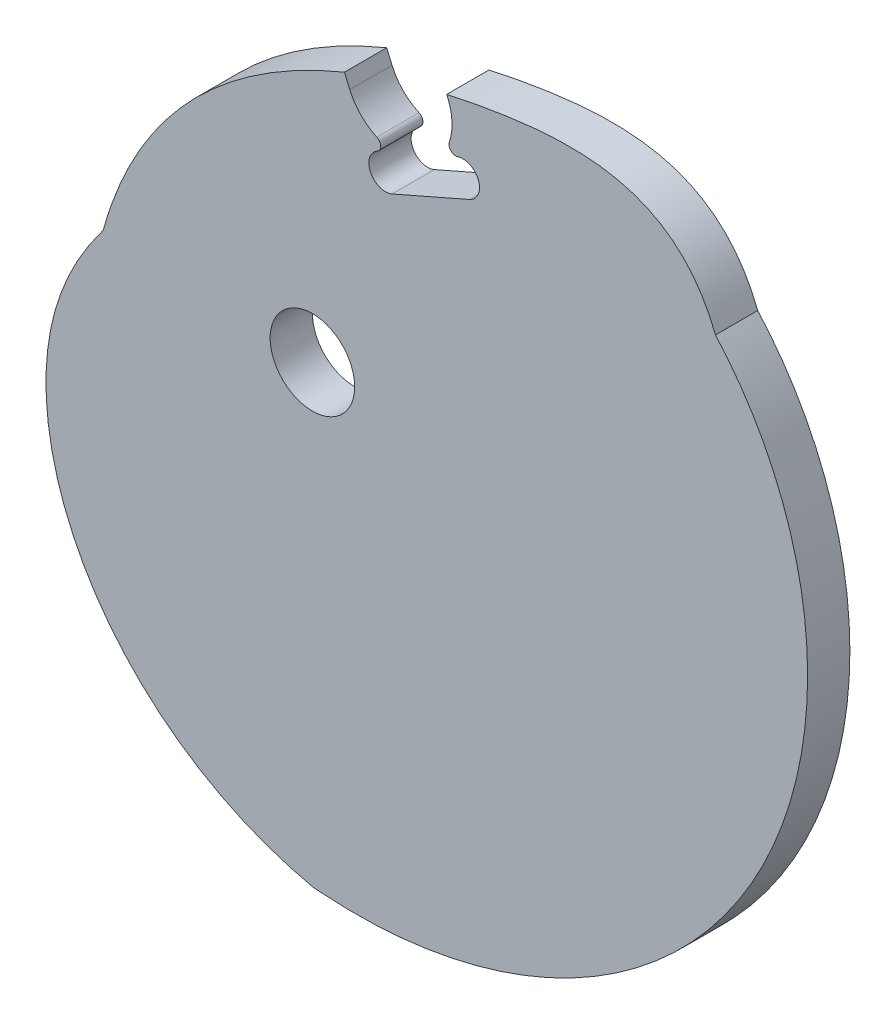
from build123d import *

# Parameters (mm, degrees)
SKETCH1_R           = 6.35
BOSS_EXTRUDE1_DEPTH = 3.175
FILLET3_R           = 1


with BuildPart() as part:
    # Sketch1 → Boss-Extrude1 (new body, symmetric)
    with BuildSketch(Plane.XY):
        with BuildLine():
            ThreePointArc((11.984914181, 27.895733584), (8.691133377, 29.180649151), (9.976048944, 32.474429955))
            Line((9.976048944, 32.474429955), (12.234616787, 33.465357952))
            ThreePointArc((12.234616787, 33.465357952), (8.260068693, 34.969173795), (5.615202157, 38.295309036))
            Line((5.615202157, 38.295309036), (4.817017743, 40.166741189))
            add(Edge.make_bspline(
                [(4.817017743, 40.166741189), (-12.318313017, 33.133186073), (-26.082330189, 20.886296157), (-31.434854064, 1.476615471)],
                knots=[0.525970045, 0.525970045, 0.525970045, 0.525970045, 1, 1, 1, 1], degree=3))
            add(Edge.make_bspline(
                [(-31.434854064, 1.476615471), (-31.527195505, 1.353858054), (-31.754298965, 1.049739376), (-32.114304, 0.558316675), (-32.5147745, -0.002107391), (-32.914270808, -0.576495389), (-33.311891924, -1.165119679), (-33.706725269, -1.768206694), (-34.097848502, -2.385936616), (-34.484331346, -3.018443117), (-34.865237427, -3.665813149), (-35.239626109, -4.328086807), (-35.606554333, -5.005257241), (-35.965078463, -5.697270632), (-36.433186951, -6.644749058), (-36.877778588, -7.616227649), (-37.403538549, -8.865808487), (-37.89844649, -10.15596349), (-38.339644059, -11.47844157), (-38.659981536, -12.561345718), (-38.883742195, -13.388599922), (-39.089211509, -14.227060001), (-39.27554788, -15.076191498), (-39.498552768, -16.225715183), (-39.726946666, -17.686700696), (-39.917996988, -19.468580741), (-40.024782444, -21.280969713), (-40.045341441, -23.119742437), (-39.9779185, -24.980664299), (-39.820968297, -26.859401742), (-39.573161339, -28.751532609), (-39.233388685, -30.652556865), (-38.800766241, -32.557907545), (-38.274638487, -34.462961931), (-37.654581673, -36.363052938), (-36.940406441, -38.253480666), (-36.132159895, -40.129524105), (-35.230127076, -41.986452952), (-34.234831872, -43.819539532), (-33.147037329, -45.624070773), (-31.967745371, -47.395360218), (-30.69819593, -49.128760047), (-29.339865478, -50.819673076), (-27.894464961, -52.463564698), (-26.363937143, -54.055974755), (-24.750453354, -55.592529291), (-23.05640966, -57.068952172), (-21.284422438, -58.481076539), (-19.437323392, -59.824856061), (-17.518153991, -61.09637597), (-15.53015936, -62.291863846), (-13.476781624, -63.407700126), (-11.361652741, -64.440428475), (-9.553831313, -65.227709289), (-8.080597677, -65.813060218), (-6.960835983, -66.230097397), (-5.828609099, -66.623940834), (-4.684517393, -66.994692102), (-3.528855098, -67.340343758), (-2.363108933, -67.666857115), (-1.184337898, -67.950379167), (-0.01402302, -68.276721004), (1.19496178, -68.321277307), (2.388869047, -68.414812178), (3.588916798, -68.47013668), (4.791045471, -68.510536097), (5.995946941, -68.529549806), (7.203027199, -68.528714145), (8.412028292, -68.507423656), (10.433152978, -68.437688056), (12.861297544, -68.271113035), (15.690066279, -67.954769994), (18.114395708, -67.598393542), (20.533178068, -67.156262739), (22.94320403, -66.627739384), (25.34117249, -66.012319379), (27.72369681, -65.309640519), (30.087311662, -64.519489877), (32.428480366, -63.641810853), (34.743602713, -62.676709846), (37.029023257, -61.624462503), (39.281040057, -60.485519541), (41.495913836, -59.26051209), (43.669877536, -57.950256553), (45.799146255, -56.555758944), (47.879927513, -55.078218686), (49.908431845, -53.519031845), (51.880883673, -51.879793783), (53.793532432, -50.162301209), (55.642663916, -48.368553607), (57.424611814, -46.500754037), (59.135769398, -44.561309278), (60.772601325, -42.552829318), (62.331655529, -40.478126172), (63.809575152, -38.340212016), (65.203110484, -36.142296645), (66.509130877, -33.887784231), (67.724636585, -31.580269399), (68.846770509, -29.223532602), (69.872829789, -26.821534809), (70.800277214, -24.378411507), (71.626752419, -21.898466018), (72.350082814, -19.386162143), (72.968294223, -16.846116143), (73.479621181, -14.283088065), (73.882516868, -11.701972429), (74.175662624, -9.107788295), (74.35797703, -6.505668721), (74.428624501, -3.900849636), (74.387023371, -1.298658146), (74.232853422, 1.295499691), (73.966062842, 3.876151621), (73.586874568, 6.437772425), (73.095791985, 8.974797617), (72.493603959, 11.481637571), (71.781389173, 13.952692039), (70.960519734, 16.382365041), (70.032664043, 18.765080076), (68.999788887, 21.095295628), (67.864160745, 23.367520924), (66.628346286, 25.576331908), (65.295212039, 27.716387387), (63.867923223, 29.782445306), (62.349941726, 31.769379124), (61.22405744, 33.104244186), (60.617225546, 33.785688077), (60.561937131, 33.847469547)],
                knots=[0.746012314, 0.746012314, 0.746012314, 0.746012314, 0.747290584, 0.749170776, 0.751081502, 0.753022336, 0.754992805, 0.756992401, 0.759020578, 0.761076761, 0.763160347, 0.76527071, 0.767407202, 0.769569155, 0.771755887, 0.776200882, 0.778457713, 0.783036392, 0.787696808, 0.790055792, 0.792432952, 0.794827532, 0.797238799, 0.799666426, 0.804570687, 0.809540165, 0.814574675, 0.819673984, 0.824837811, 0.830065834, 0.835357687, 0.840712962, 0.84613121, 0.851611942, 0.857154631, 0.862758708, 0.868423573, 0.874148584, 0.879933066, 0.885776307, 0.891677564, 0.897636058, 0.903650977, 0.909721476, 0.915846682, 0.922025687, 0.928257554, 0.934541315, 0.940875975, 0.947260508, 0.95369386, 0.960174949, 0.966702667, 0.973275876, 0.976579178, 0.979893415, 0.983218438, 0.986554095, 0.989900235, 0.993256703, 0.996623344, 1, 1.003319606, 1.00664483, 1.00997572, 1.013312315, 1.016654652, 1.020002764, 1.023356679, 1.026716422, 1.036830797, 1.043603114, 1.050398984, 1.057218364, 1.064061153, 1.070927192, 1.077816264, 1.084728096, 1.09166236, 1.098618675, 1.105596607, 1.112595671, 1.119615332, 1.126655005, 1.133714056, 1.140791804, 1.147887524, 1.155000443, 1.162129745, 1.169274569, 1.176434014, 1.183607137, 1.190792953, 1.197990441, 1.205198539, 1.212416148, 1.219642135, 1.226875331, 1.234114533, 1.241358506, 1.248605983, 1.255855669, 1.263106241, 1.270356345, 1.277604607, 1.284849627, 1.292089983, 1.299324234, 1.306550921, 1.313768569, 1.320975689, 1.328170782, 1.335352341, 1.342518853, 1.349668803, 1.356800674, 1.363912958, 1.37100415, 1.37807276, 1.385117313, 1.392136355, 1.399128458, 1.406092224, 1.413026294, 1.419929348, 1.420619252, 1.420619252, 1.420619252, 1.420619252], degree=3))
            add(Edge.make_bspline(
                [(60.561937131, 33.847469547), (54.845801337, 48.446027811), (38.415683117, 48.488850835), (22.815960401, 45.553267169), (20.179716664, 44.956820308)],
                knots=[0, 0, 0, 0, 0.323798127, 0.390810822, 0.390810822, 0.390810822, 0.390810822], degree=3))
            Line((20.179716664, 44.956820308), (20.341961861, 44.576418389))
            ThreePointArc((20.341961861, 44.576418389), (20.922430294, 40.447066038), (19.347369883, 36.586019659))
            Line((19.347369883, 36.586019659), (21.605937727, 37.576947657))
            ThreePointArc((21.605937727, 37.576947657), (24.899718531, 36.29203209), (23.614802964, 32.998251286))
            Line((23.614802964, 32.998251286), (11.984914181, 27.895733584))
        make_face()
        Circle(SKETCH1_R, mode=Mode.SUBTRACT)
    extrude(amount=BOSS_EXTRUDE1_DEPTH, both=True)

    # Fillet3
    fillet3_edges = [part.edges().sort_by_distance(p)[0] for p in [
        (12.234616787, 33.465357952, 0),
        (19.347369883, 36.586019659, 0),
    ]]
    fillet(fillet3_edges, radius=FILLET3_R)


solid = part.part
